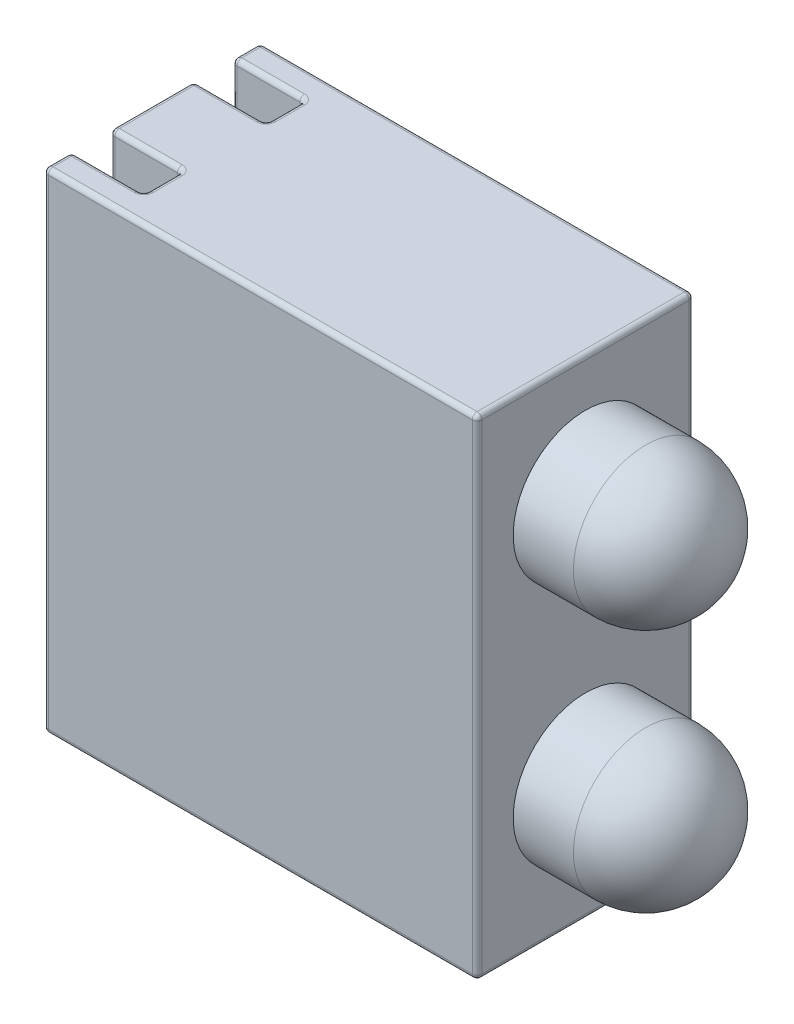
from build123d import *

# Parameters (mm, degrees)
SKETCH1_W           = 9
SKETCH1_H           = 10.16
BOSS_EXTRUDE1_DEPTH = 2.25
SKETCH2_W           = 0.8
SKETCH2_H           = 10.16
CUT_EXTRUDE1_DEPTH  = 1.5
LPATTERN1_COUNT     = 2
LPATTERN1_PITCH     = 5.08
FILLET1_R           = 0.1


with BuildPart() as part:
    # Sketch1 → Boss-Extrude1 (new body, symmetric)
    with BuildSketch(Plane.XY):
        with Locations((4.5, 5.08)):
            Rectangle(SKETCH1_W, SKETCH1_H)
    extrude(amount=BOSS_EXTRUDE1_DEPTH, both=True)

    # Sketch2 → Cut-Extrude1 (cut)
    with BuildSketch(Plane.ZY):
        with Locations((-1.27, 5.08)):
            Rectangle(SKETCH2_W, SKETCH2_H)
        with Locations((1.27, 5.08)):
            Rectangle(SKETCH2_W, SKETCH2_H)
    extrude(amount=-CUT_EXTRUDE1_DEPTH, mode=Mode.SUBTRACT)

    # Sketch3 → Revolve4 (revolve)
    with BuildSketch(Plane.XY):
        with BuildLine():
            Line((10.25, 9.16), (9, 9.16))
            Line((9, 9.16), (9, 7.66))
            Line((9, 7.66), (11.75, 7.66))
            ThreePointArc((11.75, 7.66), (11.310660172, 8.720660172), (10.25, 9.16))
        make_face()
    revolve4 = revolve(axis=Axis((11.75, 7.66, 0), (-1, 0, 0)))

    # LPattern1: Revolve4 ×2
    with Locations(*[(0, -i * LPATTERN1_PITCH, 0) for i in range(1, LPATTERN1_COUNT)]):
        add(revolve4)

    # Fillet1
    fillet1_edges = [part.edges().sort_by_distance(p)[0] for p in [
        (9, 5.08, 2.25),
        (4.5, 10.16, 2.25),
        (0, 10.16, 0),
        (0, 10.16, -1.96),
        (0, 0, 0),
        (0, 0, -1.96),
        (1.5, 5.08, -0.87),
        (0.75, 10.16, -0.87),
        (1.5, 0, -1.27),
        (0.75, 0, -0.87),
        (1.5, 5.08, -1.67),
        (0.75, 0, -1.67),
        (1.5, 10.16, -1.27),
        (0.75, 10.16, -1.67),
        (0, 5.08, -0.87),
        (0, 5.08, -1.67),
        (1.5, 5.08, 1.67),
        (0.75, 10.16, 1.67),
        (1.5, 0, 1.27),
        (0.75, 0, 1.67),
        (1.5, 5.08, 0.87),
        (0.75, 0, 0.87),
        (1.5, 10.16, 1.27),
        (0.75, 10.16, 0.87),
        (0, 5.08, 1.67),
        (0, 5.08, 0.87),
        (0, 5.08, 2.25),
        (4.5, 10.16, -2.25),
        (9, 5.08, -2.25),
        (4.5, 0, -2.25),
        (0, 5.08, -2.25),
        (4.5, 0, 2.25),
        (0, 10.16, 1.96),
        (9, 10.16, 0),
        (9, 0, 0),
        (0, 0, 1.96),
    ]]
    fillet(fillet1_edges, radius=FILLET1_R)


solid = part.part
